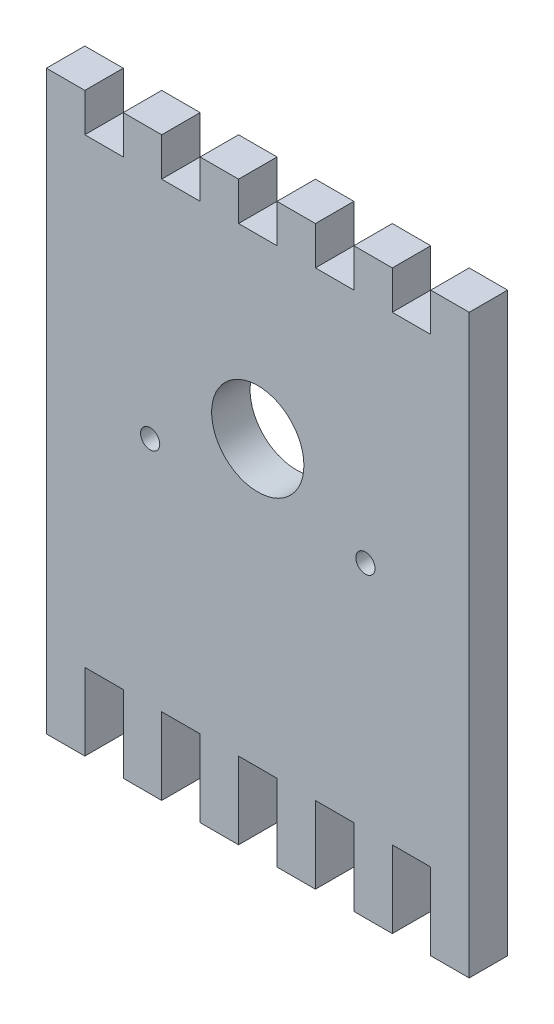
from build123d import *

# Parameters (mm, degrees)
ESQUISSE1_R        = 1.25
ESQUISSE1_R_2      = 6
BOSS_EXTRU_1_DEPTH = 5


with BuildPart() as part:
    # Esquisse1 → Boss.-Extru.1 (new body)
    with BuildSketch(Plane.XY):
        Polygon((15, 65), (10, 65), (10, 60), (5, 60), (5, 65), (0, 65), (0, -10), (5, -10), (5, 0), (10, 0), (10, -10), (15, -10), (15, 0), (20, 0), (20, -10), (25, -10), (25, 0), (30, 0), (30, -10), (35, -10), (35, 0), (40, 0), (40, -10), (45, -10), (45, 0), (50, 0), (50, -10), (55, -10), (55, 65), (50, 65), (50, 60), (45, 60), (45, 65), (40, 65), (40, 60), (35, 60), (35, 65), (30, 65), (30, 60), (25, 60), (25, 65), (20, 65), (20, 60), (15, 60), align=None)
        with Locations((41.5, 30)):
            Circle(ESQUISSE1_R, mode=Mode.SUBTRACT)
        with Locations((13.5, 30)):
            Circle(ESQUISSE1_R, mode=Mode.SUBTRACT)
        with Locations((27.5, 37)):
            Circle(ESQUISSE1_R_2, mode=Mode.SUBTRACT)
    extrude(amount=BOSS_EXTRU_1_DEPTH)


solid = part.part
